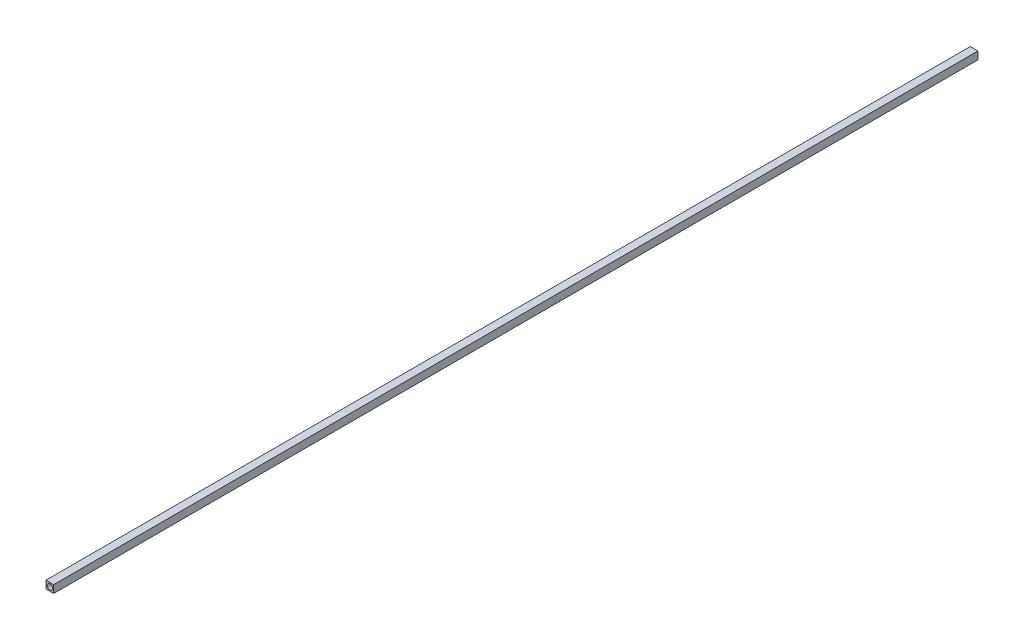
from build123d import *

# Parameters (mm, degrees)
SKETCH1_W           = 6.35
SKETCH1_H           = 6.35
SKETCH1_R           = 2.1844
BOSS_EXTRUDE1_DEPTH = 762


with BuildPart() as part:
    # Sketch1 → Boss-Extrude1 (new body)
    with BuildSketch(Plane.XY):
        Rectangle(SKETCH1_W, SKETCH1_H)
        Circle(SKETCH1_R, mode=Mode.SUBTRACT)
    extrude(amount=BOSS_EXTRUDE1_DEPTH)


solid = part.part
